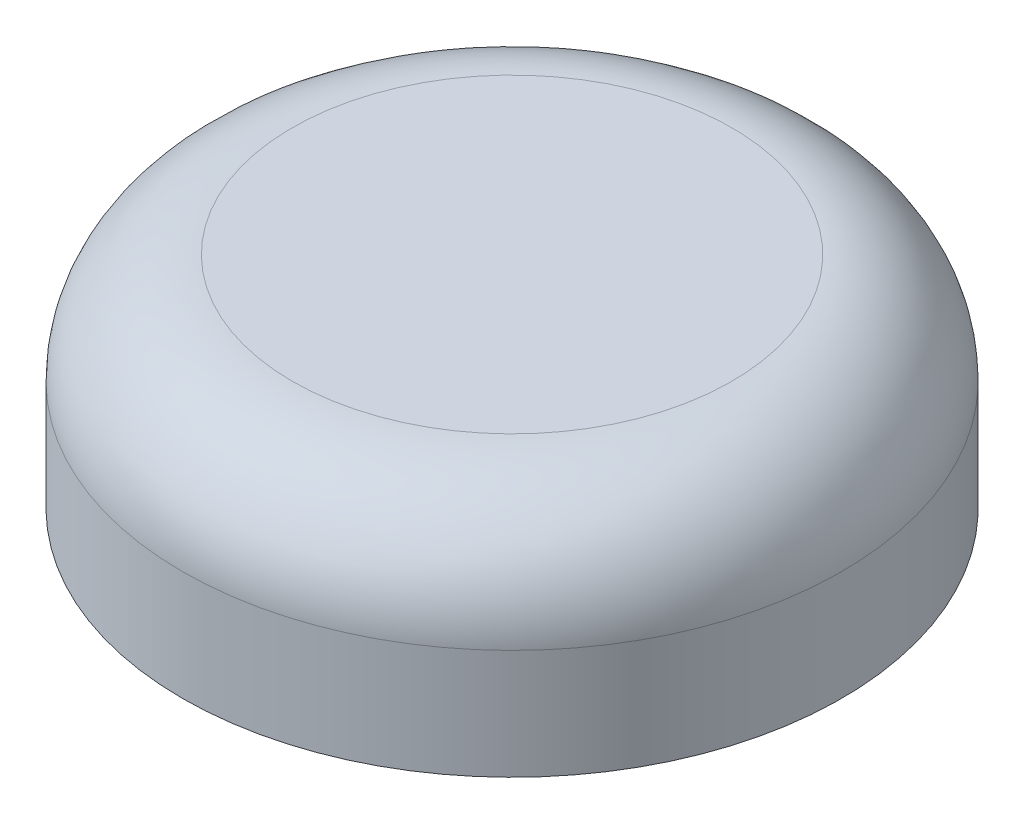
from build123d import *

# Parameters (mm, degrees)
SKETCH1_R           = 30
SKETCH1_R_2         = 15
BOSS_EXTRUDE1_DEPTH = 10
SKETCH2_R           = 30
BOSS_EXTRUDE2_DEPTH = 10
FILLET1_R           = 10


with BuildPart() as part:
    # Sketch1 → Boss-Extrude1 (new body)
    with BuildSketch(Plane(origin=(0, 0, 0), x_dir=(1, 0, 0), z_dir=(0, 1, 0))):
        Circle(SKETCH1_R)
        with BuildLine():
            ThreePointArc((2.5, 24.874685928), (0, -25), (-2.5, 24.874685928))
            Line((-2.5, 24.874685928), (-2.5, 19.843134833))
            ThreePointArc((-2.5, 19.843134833), (0, -20), (2.5, 19.843134833))
            Line((2.5, 19.843134833), (2.5, 24.874685928))
        make_face(mode=Mode.SUBTRACT)
        Circle(SKETCH1_R_2, mode=Mode.SUBTRACT)
    extrude(amount=BOSS_EXTRUDE1_DEPTH)

    # Sketch2 → Boss-Extrude2 (add)
    with BuildSketch(Plane(origin=(0, 10, 0), x_dir=(1, 0, 0), z_dir=(0, 1, 0))):
        Circle(SKETCH2_R)
    extrude(amount=BOSS_EXTRUDE2_DEPTH)

    # Fillet1
    fillet1_edges = [part.edges().sort_by_distance(p)[0] for p in [
        (-30, 20, 0),
    ]]
    fillet(fillet1_edges, radius=FILLET1_R)


solid = part.part
